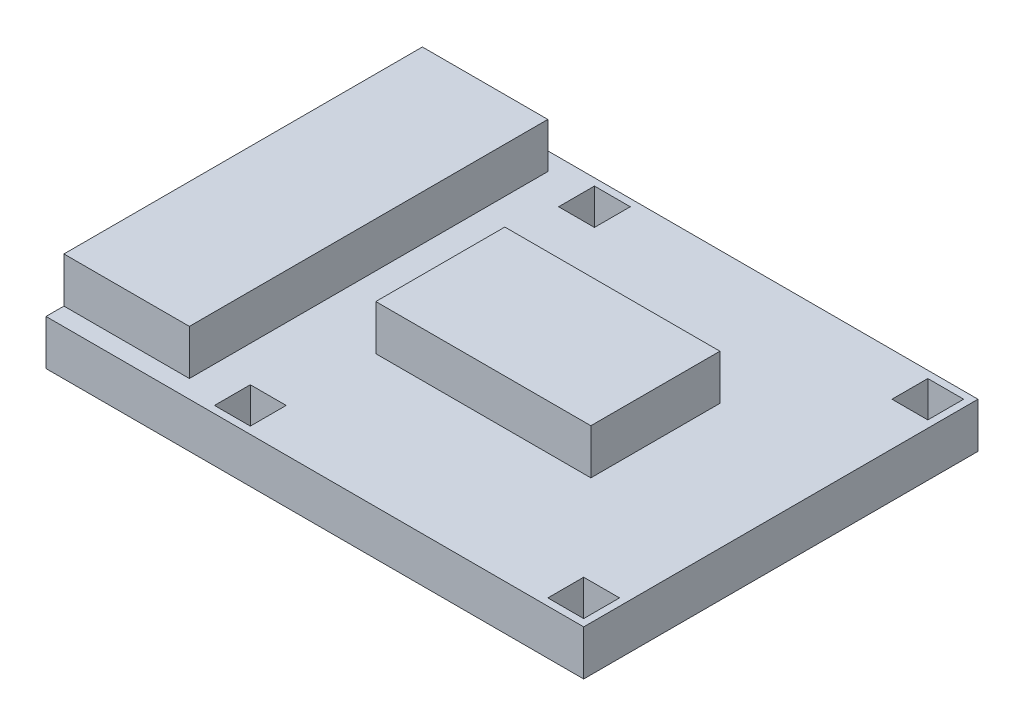
from build123d import *

# Parameters (mm, degrees)
SKETCH1_W                  = 150
SKETCH1_H                  = 110
BOSS_EXTRUDE1_DEPTH        = 1.6
SKETCH2_W                  = 150
SKETCH2_H                  = 110
SKETCH2_W_2                = 10
SKETCH2_H_2                = 10
BOSS_EXTRUDE2_DEPTH        = 11
F_4_0_4_3_DIAMETER_HOLE1_D = 4.3
SKETCH3_W                  = 35
SKETCH3_H                  = 100
BOSS_EXTRUDE3_DEPTH        = 12.6
SKETCH4_W                  = 60
SKETCH4_H                  = 36
BOSS_EXTRUDE4_DEPTH        = 12.6


with BuildPart() as part:
    # Sketch1 → Boss-Extrude1 (new body)
    with BuildSketch(Plane(origin=(0, 0, 0), x_dir=(1, 0, 0), z_dir=(0, 1, 0))):
        with Locations((75, 55)):
            Rectangle(SKETCH1_W, SKETCH1_H)
    extrude(amount=BOSS_EXTRUDE1_DEPTH)

    # Sketch2 → Boss-Extrude2 (add)
    with BuildSketch(Plane(origin=(0, 1.6, 0), x_dir=(1, 0, 0), z_dir=(0, 1, 0))):
        with Locations((75, 55)):
            Rectangle(SKETCH2_W, SKETCH2_H)
        with Locations((50, 103)):
            Rectangle(SKETCH2_W_2, SKETCH2_H_2, mode=Mode.SUBTRACT)
        with Locations((143, 103)):
            Rectangle(SKETCH2_W_2, SKETCH2_H_2, mode=Mode.SUBTRACT)
        with Locations((143, 7)):
            Rectangle(SKETCH2_W_2, SKETCH2_H_2, mode=Mode.SUBTRACT)
        with Locations((50, 7)):
            Rectangle(SKETCH2_W_2, SKETCH2_H_2, mode=Mode.SUBTRACT)
    extrude(amount=BOSS_EXTRUDE2_DEPTH)

    # Ø4.0 (4.3) Diameter Hole1 (through all)
    with Locations(Plane(origin=(0, 1.6, 0), x_dir=(1, 0, 0), z_dir=(0, 1, 0))):
        with Locations((143, 103), (50, 103), (50, 7), (143, 7)):
            Hole(F_4_0_4_3_DIAMETER_HOLE1_D / 2)

    # Sketch3 → Boss-Extrude3 (add)
    with BuildSketch(Plane(origin=(0, 12.6, 0), x_dir=(1, 0, 0), z_dir=(0, 1, 0))):
        with Locations((17.5, 55)):
            Rectangle(SKETCH3_W, SKETCH3_H)
    extrude(amount=BOSS_EXTRUDE3_DEPTH)

    # Sketch4 → Boss-Extrude4 (add)
    with BuildSketch(Plane(origin=(0, 12.6, 0), x_dir=(1, 0, 0), z_dir=(0, 1, 0))):
        with Locations((85, 55)):
            Rectangle(SKETCH4_W, SKETCH4_H)
    extrude(amount=BOSS_EXTRUDE4_DEPTH)


solid = part.part
